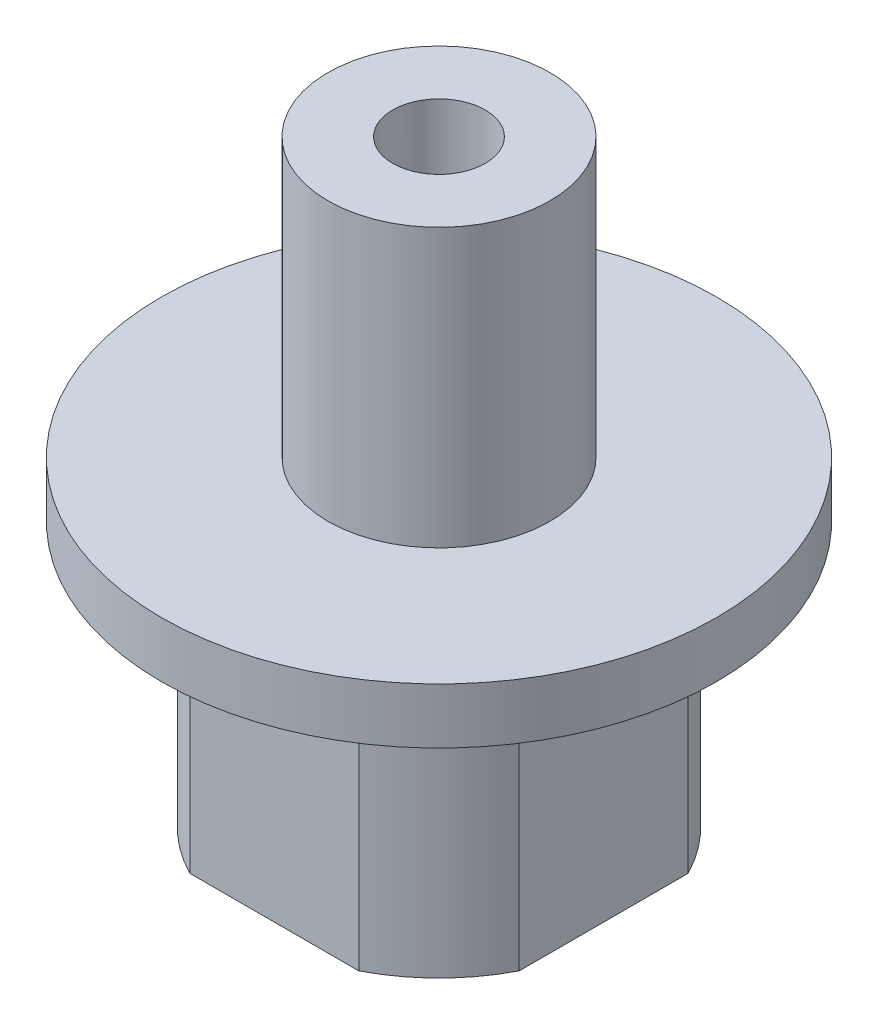
from build123d import *

# Parameters (mm, degrees)
SKETCH1_R                  = 5
SKETCH1_R_2                = 2
BOSS_EXTRUDE1_DEPTH        = 3.575
SKETCH2_R                  = 7.5
SKETCH2_R_2                = 2
BOSS_EXTRUDE2_DEPTH        = 1.5
SKETCH3_W                  = 11.269871592
SKETCH3_H                  = 12.441128044
SKETCH3_W_2                = 8.898049958
SKETCH3_H_2                = 8.898049958
CUT_EXTRUDE1_DEPTH         = 7.15
M3X0_5_TAPPED_HOLE1_REACH  = 16.993
M3X0_5_TAPPED_HOLE1_BORE_R = 1.25
SKETCH9_R                  = 3
SKETCH9_R_2                = 2
BOSS_EXTRUDE3_DEPTH        = 7.5
SKETCH11_R                 = 2
BOSS_EXTRUDE4_DEPTH        = 7.5
M3X0_5_TAPPED_HOLE2_D      = 2.5
SKETCH15_R                 = 2
SKETCH15_R_2               = 1.25
CUT_EXTRUDE2_DEPTH         = 2


with BuildPart() as part:
    # Sketch1 → Boss-Extrude1 (new, symmetric)
    with BuildSketch(Plane(origin=(0, 0, 0), x_dir=(1, 0, 0), z_dir=(0, 1, 0))):
        with Locations(Location((0, 0, 0), (0, 0, 270))):
            Circle(SKETCH1_R)
        with Locations(Location((0, 0, 0), (0, 0, 270))):
            Circle(SKETCH1_R_2, mode=Mode.SUBTRACT)
    extrude(amount=BOSS_EXTRUDE1_DEPTH, both=True)

    # Sketch2 → Boss-Extrude2 (add)
    with BuildSketch(Plane(origin=(0, 3.575, 0), x_dir=(1, 0, 0), z_dir=(0, 1, 0))):
        with Locations(Location((0, 0, 0), (0, 0, 270))):
            Circle(SKETCH2_R)
        with Locations(Location((0, 0, 0), (0, 0, 270))):
            Circle(SKETCH2_R_2, mode=Mode.SUBTRACT)
    extrude(amount=BOSS_EXTRUDE2_DEPTH)

    # Sketch3 → Cut-Extrude1 (cut)
    with BuildSketch(Plane.XZ.offset(3.575)):
        Rectangle(SKETCH3_W, SKETCH3_H)
        Rectangle(SKETCH3_W_2, SKETCH3_H_2, mode=Mode.SUBTRACT)
    extrude(amount=-CUT_EXTRUDE1_DEPTH, mode=Mode.SUBTRACT)

    # M3x0.5 Tapped Hole1 bore → M3x0.5 Tapped Hole1 (cut, up to next)
    with BuildSketch(Plane(origin=(0, 0, -4.449024979), x_dir=(-1, 0, 0), z_dir=(0, 0, -1)), mode=Mode.PRIVATE) as m3x0_5_tapped_hole1_sk1:
        with Locations((0, -0.575)):
            Circle(M3X0_5_TAPPED_HOLE1_BORE_R)
    m3x0_5_tapped_hole1_tool1 = extrude(m3x0_5_tapped_hole1_sk1.sketch, amount=-M3X0_5_TAPPED_HOLE1_REACH, mode=Mode.PRIVATE) & part.part
    add(m3x0_5_tapped_hole1_tool1.solids().sort_by_distance((0, -0.575, -4.449025))[0], mode=Mode.SUBTRACT)

    # Sketch9 → Boss-Extrude3 (add)
    with BuildSketch(Plane(origin=(0, 5.075, 0), x_dir=(1, 0, 0), z_dir=(0, 1, 0))):
        with Locations(Location((0, 0, 0), (0, 0, 270))):
            Circle(SKETCH9_R)
        with Locations(Location((0, 0, 0), (0, 0, 270))):
            Circle(SKETCH9_R_2, mode=Mode.SUBTRACT)
    extrude(amount=BOSS_EXTRUDE3_DEPTH)

    # Sketch11 → Boss-Extrude4 (add)
    with BuildSketch(Plane(origin=(0, 12.575, 0), x_dir=(1, 0, 0), z_dir=(0, 1, 0))):
        with Locations(Location((0, 0, 0), (0, 0, 270))):
            Circle(SKETCH11_R)
    extrude(amount=-BOSS_EXTRUDE4_DEPTH)

    # M3x0.5 Tapped Hole2 (through all)
    with Locations(Plane(origin=(0, 12.575, 0), x_dir=(1, 0, 0), z_dir=(0, 1, 0))):
        with Locations((0, 0)):
            Hole(M3X0_5_TAPPED_HOLE2_D / 2)

    # Sketch15 → Cut-Extrude2 (cut)
    with BuildSketch(Plane.XZ.offset(-5.075)):
        with Locations(Location((0, 0, 0), (0, 0, 270))):
            Circle(SKETCH15_R)
        with Locations(Location((0, 0, 0), (0, 0, 90))):
            Circle(SKETCH15_R_2, mode=Mode.SUBTRACT)
    extrude(amount=-CUT_EXTRUDE2_DEPTH, mode=Mode.SUBTRACT)


solid = part.part
